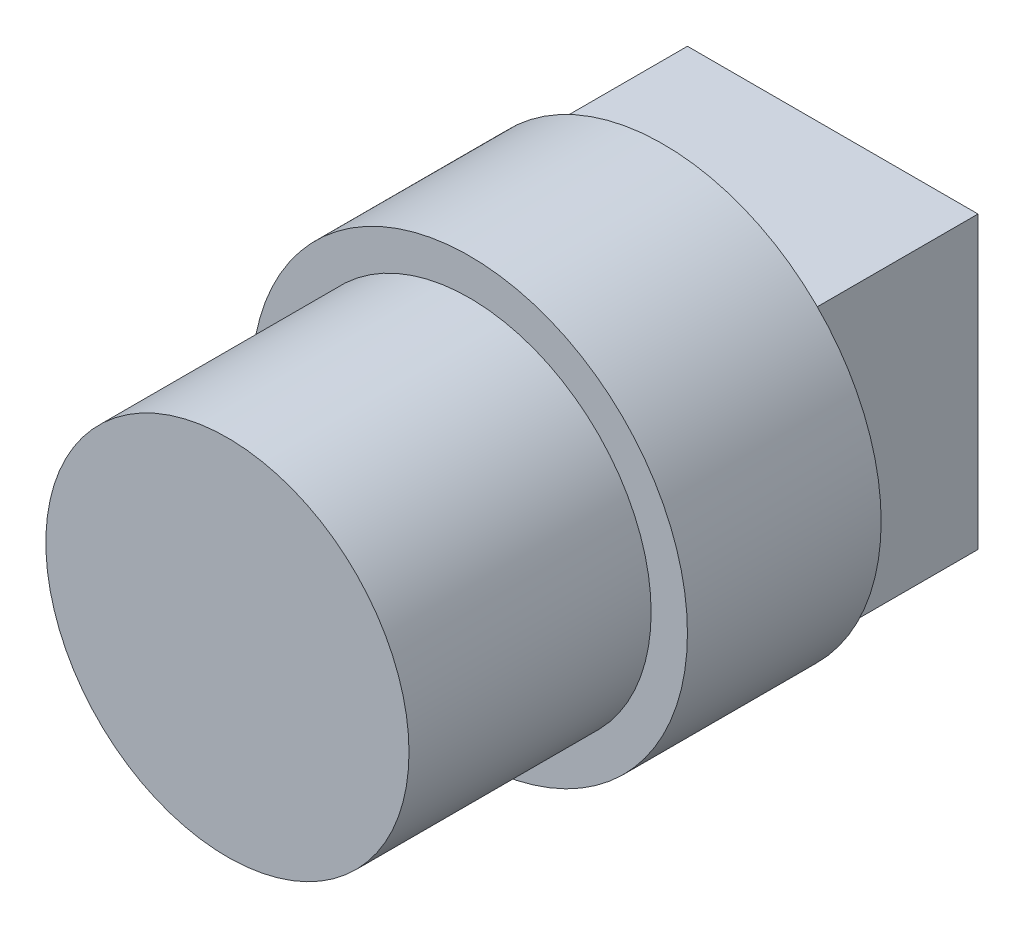
from build123d import *

# Parameters (mm, degrees)
CROQUIS1_W              = 6
CROQUIS1_H              = 6
SALIENTE_EXTRUIR1_DEPTH = 3.5
CROQUIS2_R              = 4.5
SALIENTE_EXTRUIR2_DEPTH = 4
CROQUIS3_R              = 3.75
SALIENTE_EXTRUIR3_DEPTH = 5


with BuildPart() as part:
    # Croquis1 → Saliente-Extruir1 (new body)
    with BuildSketch(Plane.XY):
        Rectangle(CROQUIS1_W, CROQUIS1_H)
    extrude(amount=SALIENTE_EXTRUIR1_DEPTH)

    # Croquis2 → Saliente-Extruir2 (add)
    with BuildSketch(Plane.XY.offset(3.5)):
        Circle(CROQUIS2_R)
    extrude(amount=SALIENTE_EXTRUIR2_DEPTH)

    # Croquis3 → Saliente-Extruir3 (add)
    with BuildSketch(Plane.XY.offset(7.5)):
        Circle(CROQUIS3_R)
    extrude(amount=SALIENTE_EXTRUIR3_DEPTH)


solid = part.part
